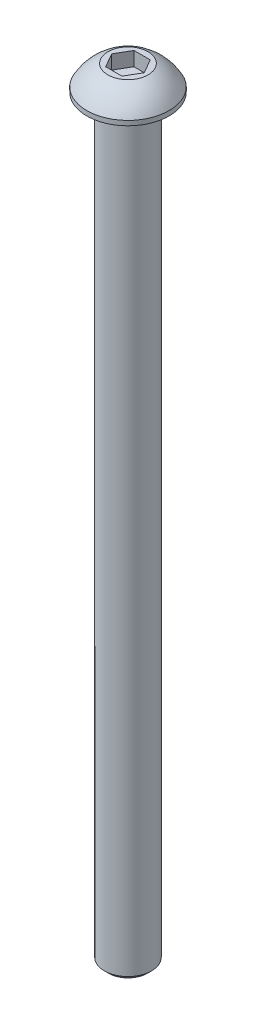
from build123d import *

# Parameters (mm, degrees)
CUT_EXTRUDE1_DEPTH = 2.38125


with BuildPart() as part:
    # Sketch1 → Base-Revolve (revolve)
    with BuildSketch(Plane.XY):
        with BuildLine():
            Line((0, -127), (3.263194444, -127))
            Line((3.263194444, -127), (3.96875, -126.294444444))
            Line((3.96875, -126.294444444), (3.96875, 0))
            Line((3.96875, 0), (6.9469, 0))
            Line((6.9469, 0), (6.9469, 0.7874))
            ThreePointArc((6.9469, 0.7874), (5.442852348, 2.789756108), (3.384630657, 4.2164))
            Line((3.384630657, 4.2164), (0, 4.2164))
            Line((0, 4.2164), (0, -127))
        make_face()
    revolve(axis=Axis((0, 69.088, 0), (0, -1, 0)))

    # Sketch2 → Cut-Extrude1 (cut)
    with BuildSketch(Plane(origin=(0, 4.2164, 0), x_dir=(-1, 0, 0), z_dir=(0, 1, 0))):
        Polygon((-2.749630657, 0), (-1.374815329, -2.38125), (1.374815329, -2.38125), (2.749630657, 0), (1.374815329, 2.38125), (-1.374815329, 2.38125), align=None)
    extrude(amount=-CUT_EXTRUDE1_DEPTH, mode=Mode.SUBTRACT)


solid = part.part
